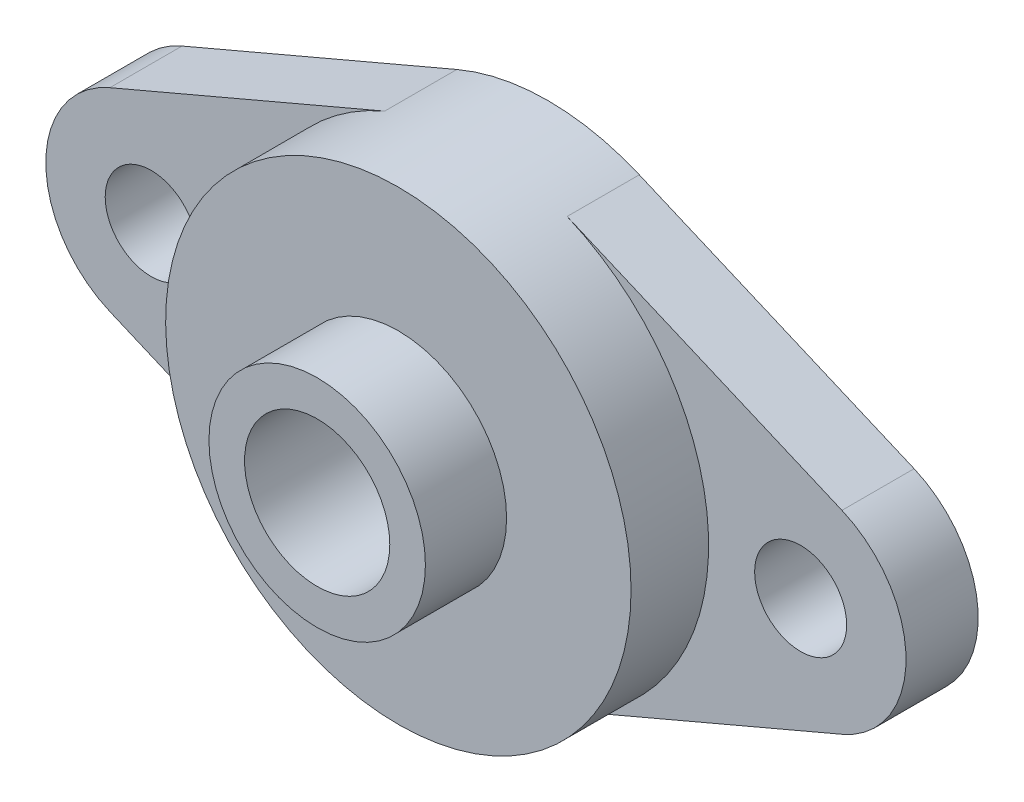
from build123d import *

# Parameters (mm, degrees)
SKETCH_1_R          = 12.9
EXTRUDE_1_DEPTH     = 8.3
SKETCH_2_R          = 6
EXTRUDE_2_DEPTH     = 4.5
SKETCH_3_R          = 4.025
CUT_EXTRUDE_1_DEPTH = 25
EXTRUDE_3_DEPTH     = 4
SKETCH_6_R          = 2.55
CUT_EXTRUDE_3_DEPTH = 13.8
SKETCH_7_R          = 4.025
CUT_EXTRUDE_4_DEPTH = 13.8


with BuildPart() as part:
    # 草图1 → 凸台-拉伸1 (new body)
    with BuildSketch(Plane.XY):
        Circle(SKETCH_1_R)
    extrude(amount=EXTRUDE_1_DEPTH)

    # 草图2 → 凸台-拉伸2 (add)
    with BuildSketch(Plane.XY.offset(8.3)):
        Circle(SKETCH_2_R)
    extrude(amount=EXTRUDE_2_DEPTH)

    # 草图3 → 切除-拉伸1 (cut)
    with BuildSketch(Plane.XY.offset(12.8)):
        Circle(SKETCH_3_R)
    extrude(amount=-CUT_EXTRUDE_1_DEPTH, mode=Mode.SUBTRACT)

    # 草图4 → 凸台-拉伸3 (add)
    with BuildSketch(Plane(origin=(0, 0, 0), x_dir=(-1, 0, 0), z_dir=(0, 0, -1))):
        with BuildLine():
            Line((-5.057343549, 11.867319673), (-20.2907969, 5.375474071))
            ThreePointArc((-20.2907969, 5.375474071), (-23.843241559, 0), (-20.2907969, -5.375474071))
            Line((-20.2907969, -5.375474071), (-5.057343549, -11.867319673))
            ThreePointArc((-5.057343549, -11.867319673), (0, -12.9), (5.057343549, -11.867319673))
            Line((5.057343549, -11.867319673), (20.2907969, -5.375474071))
            ThreePointArc((20.2907969, -5.375474071), (23.843241559, 0), (20.2907969, 5.375474071))
            Line((20.2907969, 5.375474071), (5.057343549, 11.867319673))
            ThreePointArc((5.057343549, 11.867319673), (0, 12.9), (-5.057343549, 11.867319673))
        make_face()
    extrude(amount=-EXTRUDE_3_DEPTH)

    # 草图6 → 切除-拉伸3 (cut, through all)
    with BuildSketch(Plane(origin=(0, 0, 0), x_dir=(-1, 0, 0), z_dir=(0, 0, -1))):
        with Locations((-18, 0)):
            Circle(SKETCH_6_R)
        with Locations((18, 0)):
            Circle(SKETCH_6_R)
    extrude(amount=-CUT_EXTRUDE_3_DEPTH, mode=Mode.SUBTRACT)

    # 草图7 → 切除-拉伸4 (cut, through all)
    with BuildSketch(Plane(origin=(0, 0, 0), x_dir=(-1, 0, 0), z_dir=(0, 0, -1))):
        Circle(SKETCH_7_R)
    extrude(amount=-CUT_EXTRUDE_4_DEPTH, mode=Mode.SUBTRACT)


solid = part.part
